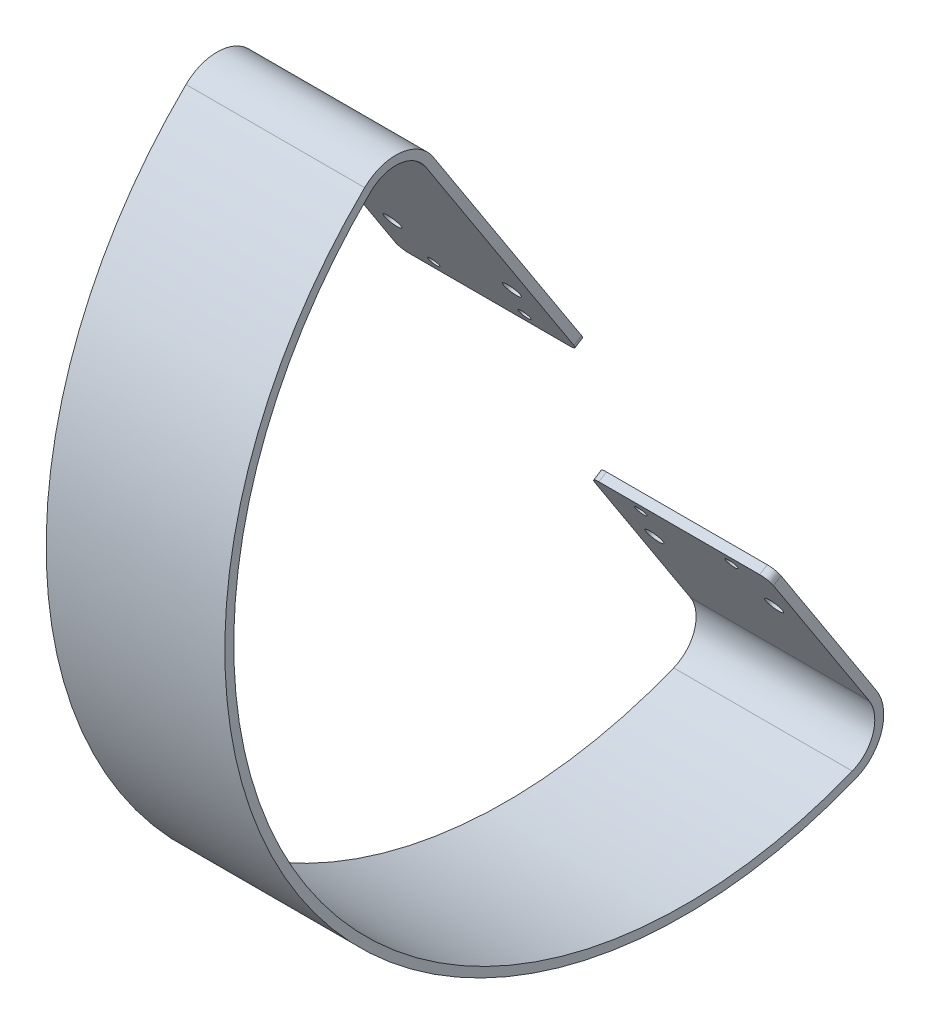
from build123d import *

# Parameters (mm, degrees)
EXTRUDE_THIN1_DEPTH = 25.4
CUT_EXTRUDE1_REACH  = 172.75
SKETCH5_RX          = 2.38125
SKETCH5_RY          = 2.381249971
SKETCH5_RX_2        = 1.550642295
SKETCH5_RY_2        = 1.550642276
SKETCH5_RX_3        = 1.646158252
SKETCH5_RY_3        = 1.646158232
FILLET1_R           = 2.54


with BuildPart() as part:
    # Sketch2 → Extrude-Thin1 (new body, symmetric)
    with BuildSketch(Plane(origin=(1981.2, 0, 0), x_dir=(0, 0, -1), z_dir=(1, 0, 0))):
        with BuildLine():
            Line((220.466063539, 151.267804305), (176.948936788, 218.39459013))
            ThreePointArc((176.948936788, 218.39459013), (167.722867176, 224.105285456), (157.452600901, 220.60470947))
            ThreePointArc((157.452600901, 220.60470947), (138.741359143, 55.545453365), (297.061605662, 5.252629462))
            ThreePointArc((297.061605662, 5.252629462), (304.44942683, 13.199484184), (303.002052812, 23.952972457))
            Line((303.002052812, 23.952972457), (274.455306754, 67.987389518))
            Line((274.455306754, 67.987389518), (272.32398896, 66.605693293))
            Line((272.32398896, 66.605693293), (300.870735018, 22.571276232))
            ThreePointArc((300.870735018, 22.571276232), (302.028634232, 13.968485614), (296.118377298, 7.611001836))
            ThreePointArc((296.118377298, 7.611001836), (140.872676937, 56.927149591), (159.220550284, 218.780989377))
            ThreePointArc((159.220550284, 218.780989377), (167.436763304, 221.581450166), (174.817618993, 217.012893905))
            Line((174.817618993, 217.012893905), (218.334745745, 149.88610808))
            Line((218.334745745, 149.88610808), (220.466063539, 151.267804305))
        make_face()
    extrude(amount=EXTRUDE_THIN1_DEPTH, both=True)

    # Sketch5 → Cut-Extrude1 (cut, up to next)
    with BuildSketch(Plane(origin=(0, 145.393223301, -224.274452143), x_dir=(-1, 0, 0), z_dir=(0, 0.543974892, -0.839101494)), mode=Mode.PRIVATE) as cut_extrude1_sk1:
        with Locations(Location((-1997.906331803, -111.078184062), (0, 0, 180))):
            Ellipse(SKETCH5_RX, SKETCH5_RY)
    cut_extrude1_tool1 = extrude(cut_extrude1_sk1.sketch, amount=-CUT_EXTRUDE1_REACH, mode=Mode.PRIVATE) & part.part
    add(cut_extrude1_tool1.solids().sort_by_distance((1997.906332, 52.187353, -284.698195))[0], mode=Mode.SUBTRACT)
    # Sketch5 → Cut-Extrude1 (cut, up to next)
    with BuildSketch(Plane(origin=(0, 145.393223301, -224.274452143), x_dir=(-1, 0, 0), z_dir=(0, 0.543974892, -0.839101494)), mode=Mode.PRIVATE) as cut_extrude1_sk2:
        with Locations(Location((-1963.906331803, -111.078300707), (0, 0, 180))):
            Ellipse(SKETCH5_RX, SKETCH5_RY)
    cut_extrude1_tool2 = extrude(cut_extrude1_sk2.sketch, amount=-CUT_EXTRUDE1_REACH, mode=Mode.PRIVATE) & part.part
    add(cut_extrude1_tool2.solids().sort_by_distance((1963.906332, 52.187255, -284.698259))[0], mode=Mode.SUBTRACT)
    # Sketch5 → Cut-Extrude1 (cut, up to next)
    with BuildSketch(Plane(origin=(0, 145.393223301, -224.274452143), x_dir=(-1, 0, 0), z_dir=(0, 0.543974892, -0.839101494)), mode=Mode.PRIVATE) as cut_extrude1_sk3:
        with Locations(Location((-1967.840481597, -96.661495239), (0, 0, 0))):
            Ellipse(SKETCH5_RX_2, SKETCH5_RY_2)
    cut_extrude1_tool3 = extrude(cut_extrude1_sk3.sketch, amount=-CUT_EXTRUDE1_REACH, mode=Mode.PRIVATE) & part.part
    add(cut_extrude1_tool3.solids().sort_by_distance((1967.840482, 64.284418, -276.855879))[0], mode=Mode.SUBTRACT)
    # Sketch5 → Cut-Extrude1 (cut, up to next)
    with BuildSketch(Plane(origin=(0, 145.393223301, -224.274452143), x_dir=(-1, 0, 0), z_dir=(0, 0.543974892, -0.839101494)), mode=Mode.PRIVATE) as cut_extrude1_sk4:
        with Locations(Location((-1993.656290613, -96.661406671), (0, 0, 0))):
            Ellipse(SKETCH5_RX_3, SKETCH5_RY_3)
    cut_extrude1_tool4 = extrude(cut_extrude1_sk4.sketch, amount=-CUT_EXTRUDE1_REACH, mode=Mode.PRIVATE) & part.part
    add(cut_extrude1_tool4.solids().sort_by_distance((1993.656291, 64.284493, -276.85583))[0], mode=Mode.SUBTRACT)
    # Sketch5 → Cut-Extrude1 (cut, up to next)
    with BuildSketch(Plane(origin=(0, 145.393223301, -224.274452143), x_dir=(-1, 0, 0), z_dir=(0, 0.543974892, -0.839101494)), mode=Mode.PRIVATE) as cut_extrude1_sk5:
        with Locations(Location((-1967.840110504, 11.504920485), (0, 0, 180))):
            Ellipse(SKETCH5_RX_2, SKETCH5_RY_2)
    cut_extrude1_tool5 = extrude(cut_extrude1_sk5.sketch, amount=-CUT_EXTRUDE1_REACH, mode=Mode.PRIVATE) & part.part
    add(cut_extrude1_tool5.solids().sort_by_distance((1967.840111, 155.047019, -218.016064))[0], mode=Mode.SUBTRACT)
    # Sketch5 → Cut-Extrude1 (cut, up to next)
    with BuildSketch(Plane(origin=(0, 145.393223301, -224.274452143), x_dir=(-1, 0, 0), z_dir=(0, 0.543974892, -0.839101494)), mode=Mode.PRIVATE) as cut_extrude1_sk6:
        with Locations(Location((-1993.655919521, 11.505009053), (0, 0, 180))):
            Ellipse(SKETCH5_RX_3, SKETCH5_RY_3)
    cut_extrude1_tool6 = extrude(cut_extrude1_sk6.sketch, amount=-CUT_EXTRUDE1_REACH, mode=Mode.PRIVATE) & part.part
    add(cut_extrude1_tool6.solids().sort_by_distance((1993.65592, 155.047094, -218.016016))[0], mode=Mode.SUBTRACT)
    # Sketch5 → Cut-Extrude1 (cut, up to next)
    with BuildSketch(Plane(origin=(0, 145.393223301, -224.274452143), x_dir=(-1, 0, 0), z_dir=(0, 0.543974892, -0.839101494)), mode=Mode.PRIVATE) as cut_extrude1_sk7:
        with Locations(Location((-1963.90586179, 25.921697621), (0, 0, 180))):
            Ellipse(SKETCH5_RX, SKETCH5_RY)
    cut_extrude1_tool7 = extrude(cut_extrude1_sk7.sketch, amount=-CUT_EXTRUDE1_REACH, mode=Mode.PRIVATE) & part.part
    add(cut_extrude1_tool7.solids().sort_by_distance((1963.905862, 167.144158, -210.173699))[0], mode=Mode.SUBTRACT)
    # Sketch5 → Cut-Extrude1 (cut, up to next)
    with BuildSketch(Plane(origin=(0, 145.393223301, -224.274452143), x_dir=(-1, 0, 0), z_dir=(0, 0.543974892, -0.839101494)), mode=Mode.PRIVATE) as cut_extrude1_sk8:
        with Locations(Location((-1997.90586179, 25.921814267), (0, 0, 180))):
            Ellipse(SKETCH5_RX, SKETCH5_RY)
    cut_extrude1_tool8 = extrude(cut_extrude1_sk8.sketch, amount=-CUT_EXTRUDE1_REACH, mode=Mode.PRIVATE) & part.part
    add(cut_extrude1_tool8.solids().sort_by_distance((1997.905862, 167.144256, -210.173636))[0], mode=Mode.SUBTRACT)

    # Fillet1
    fillet1_edges = [part.edges().sort_by_distance(p)[0] for p in [
        (1955.8, 67.296541405, -273.389647857),
        (1955.8, 150.576956192, -219.400404642),
        (2006.6, 67.296541405, -273.389647857),
        (2006.6, 150.576956192, -219.400404642),
    ]]
    fillet(fillet1_edges, radius=FILLET1_R)


solid = part.part
